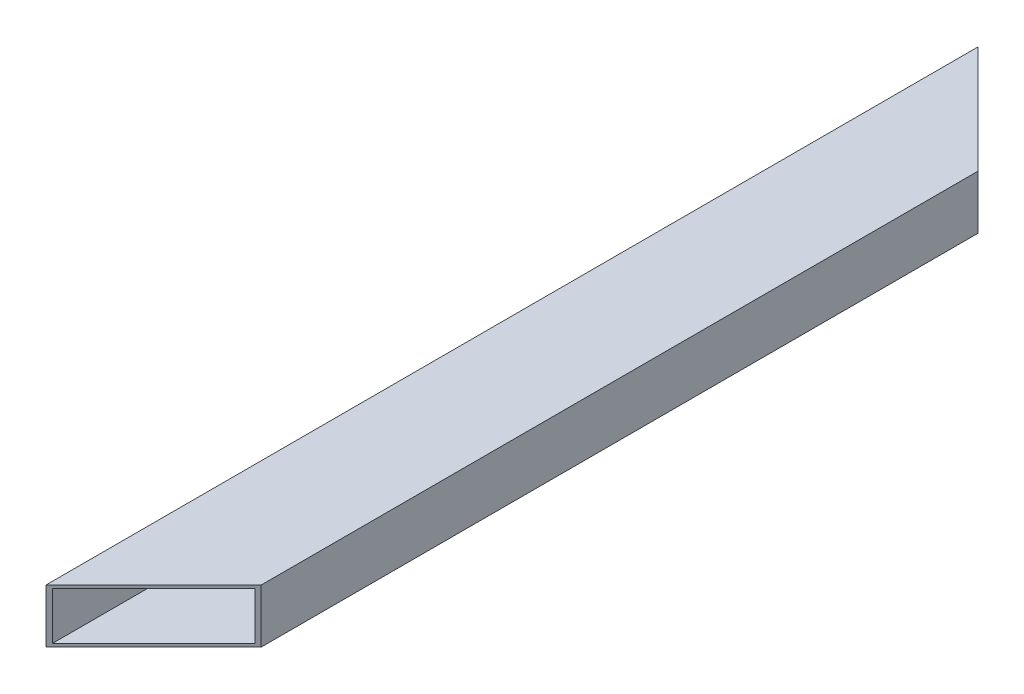
from build123d import *

# Parameters (mm, degrees)
CROQUIS1_W              = 50.8
CROQUIS1_H              = 25.4
CROQUIS1_W_2            = 47.8
CROQUIS1_H_2            = 22.4
SALIENTE_EXTRUIR1_DEPTH = 440
CORTAR_EXTRUIR1_DEPTH   = 26


with BuildPart() as part:
    # Croquis1 → Saliente-Extruir1 (new body)
    with BuildSketch(Plane.XY):
        Rectangle(CROQUIS1_W, CROQUIS1_H)
        Rectangle(CROQUIS1_W_2, CROQUIS1_H_2, mode=Mode.SUBTRACT)
    extrude(amount=SALIENTE_EXTRUIR1_DEPTH)

    # Croquis2 → Cortar-Extruir1 (cut)
    with BuildSketch(Plane(origin=(0, 12.7, 0), x_dir=(1, 0, 0), z_dir=(0, 1, 0))):
        Polygon((-25.4, 0), (25.4, -50.8), (25.4, 0), align=None)
        Polygon((25.4, -389.2), (25.4, -440), (-25.4, -440), align=None)
    extrude(amount=-CORTAR_EXTRUIR1_DEPTH, mode=Mode.SUBTRACT)


solid = part.part
